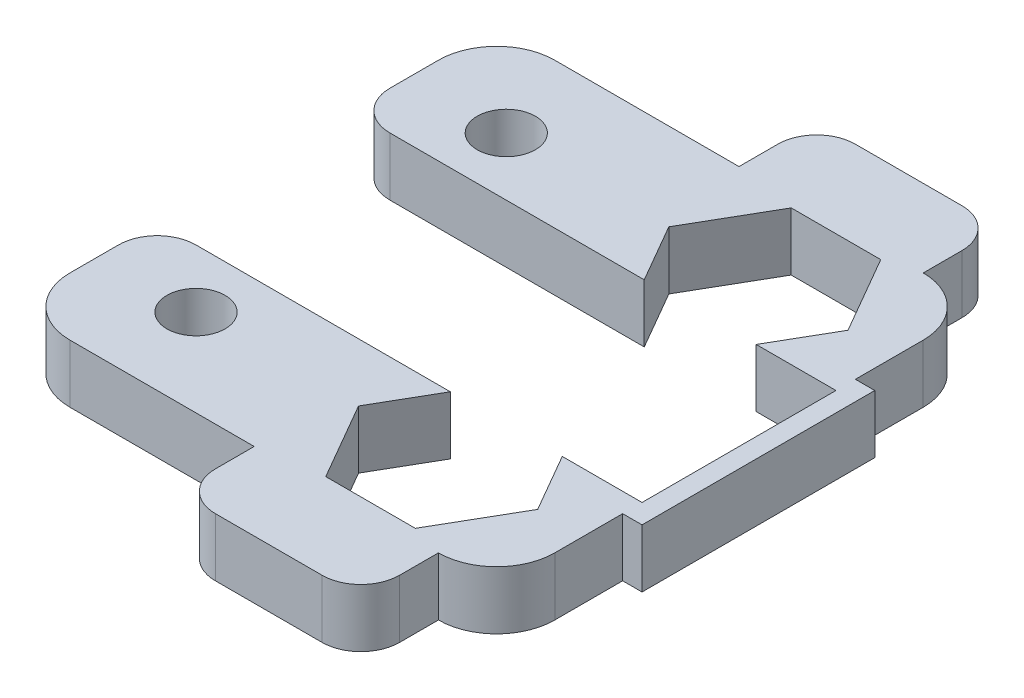
from build123d import *

# Parameters (mm, degrees)
SKETCH3_R           = 1.5
BOSS_EXTRUDE1_DEPTH = 3


with BuildPart() as part:
    # Sketch3 → Boss-Extrude1 (new body)
    with BuildSketch(Plane(origin=(0, 0, 0), x_dir=(1, 0, 0), z_dir=(0, 1, 0))):
        with BuildLine():
            Line((-60.745672261, 16.978901462), (-60.745672261, 18.978901462))
            ThreePointArc((-60.745672261, 18.978901462), (-60.159885823, 20.393115024), (-58.745672261, 20.978901462))
            Line((-58.745672261, 20.978901462), (-53.245672261, 20.978901462))
            ThreePointArc((-53.245672261, 20.978901462), (-51.831458698, 20.393115024), (-51.245672261, 18.978901462))
            Line((-51.245672261, 18.978901462), (-51.245672261, 16.978901462))
            ThreePointArc((-51.245672261, 16.978901462), (-49.124351917, 16.100221806), (-48.245672261, 13.978901462))
            Line((-48.245672261, 13.978901462), (-48.245672261, 10.478901462))
            Line((-48.245672261, 10.478901462), (-47.245672261, 10.478901462))
            Line((-47.245672261, 10.478901462), (-47.245672261, -1.521098538))
            Line((-47.245672261, -1.521098538), (-48.245672261, -1.521098538))
            Line((-48.245672261, -1.521098538), (-48.245672261, -5.021098538))
            ThreePointArc((-48.245672261, -5.021098538), (-49.124351917, -7.142418882), (-51.245672261, -8.021098538))
            Line((-51.245672261, -8.021098538), (-51.245672261, -10.021098538))
            ThreePointArc((-51.245672261, -10.021098538), (-51.831458698, -11.4353121), (-53.245672261, -12.021098538))
            Line((-53.245672261, -12.021098538), (-58.745672261, -12.021098538))
            ThreePointArc((-58.745672261, -12.021098538), (-60.159885823, -11.4353121), (-60.745672261, -10.021098538))
            Line((-60.745672261, -10.021098538), (-60.745672261, -8.021098538))
            Line((-60.745672261, -8.021098538), (-70.245672261, -8.021098538))
            ThreePointArc((-70.245672261, -8.021098538), (-72.366992604, -7.142418882), (-73.245672261, -5.021098538))
            Line((-73.245672261, -5.021098538), (-73.245672261, -2.521098538))
            ThreePointArc((-73.245672261, -2.521098538), (-72.659885823, -1.106884976), (-71.245672261, -0.521098538))
            Line((-71.245672261, -0.521098538), (-58.132423607, -0.521098538))
            Line((-58.132423607, -0.521098538), (-59.864474414, -3.521098538))
            Line((-59.864474414, -3.521098538), (-57.555073337, -7.521098538))
            Line((-57.555073337, -7.521098538), (-52.936271184, -7.521098538))
            Line((-52.936271184, -7.521098538), (-50.626870107, -3.521098538))
            Line((-50.626870107, -3.521098538), (-52.358920915, -0.521098538))
            Line((-52.358920915, -0.521098538), (-48.245672261, -0.521098538))
            Line((-48.245672261, -0.521098538), (-48.245672261, 9.478901462))
            Line((-48.245672261, 9.478901462), (-52.358920915, 9.478901462))
            Line((-52.358920915, 9.478901462), (-50.626870107, 12.478901462))
            Line((-50.626870107, 12.478901462), (-52.936271184, 16.478901462))
            Line((-52.936271184, 16.478901462), (-57.555073337, 16.478901462))
            Line((-57.555073337, 16.478901462), (-59.864474414, 12.478901462))
            Line((-59.864474414, 12.478901462), (-58.132423607, 9.478901462))
            Line((-58.132423607, 9.478901462), (-71.245672261, 9.478901462))
            ThreePointArc((-71.245672261, 9.478901462), (-72.659885823, 10.0646879), (-73.245672261, 11.478901462))
            Line((-73.245672261, 11.478901462), (-73.245672261, 13.978901462))
            ThreePointArc((-73.245672261, 13.978901462), (-72.366992604, 16.100221806), (-70.245672261, 16.978901462))
            Line((-70.245672261, 16.978901462), (-60.745672261, 16.978901462))
        make_face()
        with Locations((-68.245672261, -3.521098538)):
            Circle(SKETCH3_R, mode=Mode.SUBTRACT)
        with Locations((-68.245672261, 12.478901462)):
            Circle(SKETCH3_R, mode=Mode.SUBTRACT)
    extrude(amount=BOSS_EXTRUDE1_DEPTH)


solid = part.part
